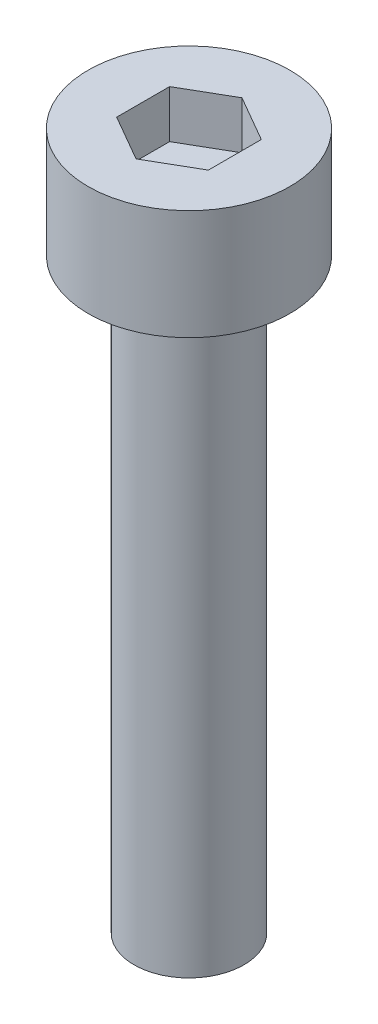
from build123d import *

# Parameters (mm, degrees)
SKETCH1_R           = 2.75
BOSS_EXTRUDE1_DEPTH = 3
CUT_EXTRUDE1_DEPTH  = 1.3
SKETCH3_R           = 1.5
BOSS_EXTRUDE2_DEPTH = 16


with BuildPart() as part:
    # Sketch1 → Boss-Extrude1 (new body)
    with BuildSketch(Plane(origin=(0, 0, 0), x_dir=(1, 0, 0), z_dir=(0, 1, 0))):
        Circle(SKETCH1_R)
    extrude(amount=BOSS_EXTRUDE1_DEPTH)

    # Sketch2 → Cut-Extrude1 (cut)
    with BuildSketch(Plane(origin=(0, 3, 0), x_dir=(1, 0, 0), z_dir=(0, 1, 0))):
        Polygon((0, 1.443375673), (-1.25, 0.721687836), (-1.25, -0.721687836), (0, -1.443375673), (1.25, -0.721687836), (1.25, 0.721687836), align=None)
    extrude(amount=-CUT_EXTRUDE1_DEPTH, mode=Mode.SUBTRACT)

    # Sketch3 → Boss-Extrude2 (add)
    with BuildSketch(Plane.XZ):
        Circle(SKETCH3_R)
    extrude(amount=BOSS_EXTRUDE2_DEPTH)


solid = part.part
